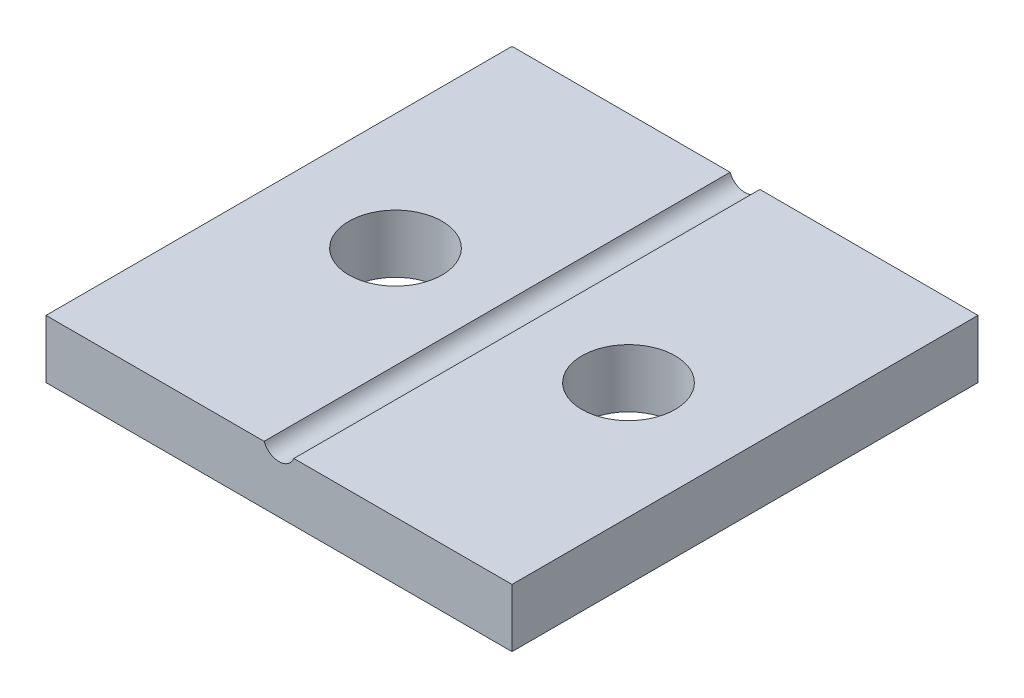
from build123d import *

# Parameters (mm, degrees)
SKETCH1_W           = 20
SKETCH1_H           = 20
BOSS_EXTRUDE1_DEPTH = 2.5
SKETCH2_R           = 0.6858
CUT_EXTRUDE1_DEPTH  = 21
SKETCH3_R           = 2
CUT_EXTRUDE2_DEPTH  = 3.5


with BuildPart() as part:
    # Sketch1 → Boss-Extrude1 (new body)
    with BuildSketch(Plane(origin=(0, 0, 0), x_dir=(1, 0, 0), z_dir=(0, 1, 0))):
        with Locations((-50.754716981, 42.075471698)):
            Rectangle(SKETCH1_W, SKETCH1_H)
    extrude(amount=BOSS_EXTRUDE1_DEPTH)

    # Sketch2 → Cut-Extrude1 (cut, through all)
    with BuildSketch(Plane.XY.offset(-32.075471698)):
        with Locations((-50.754716981, 2.75)):
            Circle(SKETCH2_R)
    extrude(amount=-CUT_EXTRUDE1_DEPTH, mode=Mode.SUBTRACT)

    # Sketch3 → Cut-Extrude2 (cut, through all)
    with BuildSketch(Plane(origin=(0, 2.5, 0), x_dir=(1, 0, 0), z_dir=(0, 1, 0))):
        with Locations((-55.754716981, 42.075471698)):
            Circle(SKETCH3_R)
        with Locations((-45.754716981, 42.075471698)):
            Circle(SKETCH3_R)
    extrude(amount=-CUT_EXTRUDE2_DEPTH, mode=Mode.SUBTRACT)


solid = part.part
